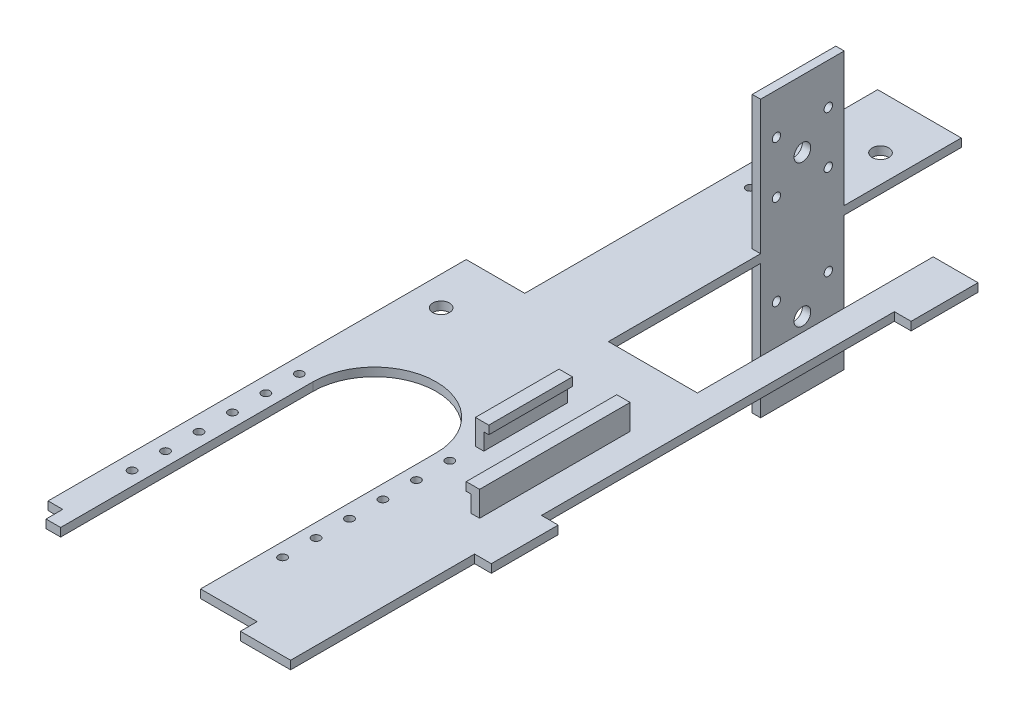
from build123d import *

# Parameters (mm, degrees)
SKETCH1_W                = 60
SKETCH1_H                = 5
BOSS_EXTRUDE1_DEPTH      = 391
SKETCH3_W                = 250
SKETCH3_H                = 5
BOSS_EXTRUDE2_DEPTH      = 95
SKETCH4_R                = 2.5
CUT_EXTRUDE1_DEPTH       = 95
SKETCH5_W                = 50
SKETCH5_H                = 141
BOSS_EXTRUDE3_DEPTH      = 5
SKETCH6_W                = 5
SKETCH6_H                = 50
BOSS_EXTRUDE4_DEPTH      = 80
SKETCH7_R                = 5
CUT_EXTRUDE2_DEPTH       = 40
CUT_EXTRUDE3_DEPTH       = 10
SKETCH11_W               = 40
SKETCH11_H               = 5
BOSS_EXTRUDE5_DEPTH      = 10
SKETCH12_W               = 30
SKETCH12_H               = 5
SKETCH12_W_2             = 17.5
BOSS_EXTRUDE6_DEPTH      = 10
SKETCH14_W               = 9
SKETCH14_H               = 5
CUT_EXTRUDE4_DEPTH       = 10
SKETCH15_W               = 5
SKETCH15_H               = 90
SKETCH15_H_2             = 50
BOSS_EXTRUDE7_DEPTH      = 15
BOSS_EXTRUDE7_DEPTH_BACK = 20
SKETCH16_W               = 50
SKETCH16_H               = 5
BOSS_EXTRUDE8_DEPTH      = 3
SKETCH18_W               = 90
SKETCH18_H               = 5
BOSS_EXTRUDE9_DEPTH      = 3
SKETCH19_R               = 2.5
CUT_EXTRUDE5_DEPTH       = 28
SKETCH20_W               = 50
SKETCH20_H               = 4.954602057
BOSS_EXTRUDE10_DEPTH     = 70
SKETCH21_R               = 5
CUT_EXTRUDE6_DEPTH       = 70
SKETCH22_R               = 2.5
CUT_EXTRUDE7_DEPTH       = 10
SKETCH23_R               = 5
CUT_EXTRUDE8_DEPTH       = 10


with BuildPart() as part:
    # Sketch1 → Boss-Extrude1 (new body)
    with BuildSketch(Plane.XY):
        Rectangle(SKETCH1_W, SKETCH1_H)
    extrude(amount=BOSS_EXTRUDE1_DEPTH)

    # Sketch3 → Boss-Extrude2 (add)
    with BuildSketch(Plane.ZY.offset(30)):
        with Locations((266, 0)):
            Rectangle(SKETCH3_W, SKETCH3_H)
    extrude(amount=BOSS_EXTRUDE2_DEPTH)

    # Sketch4 → Cut-Extrude1 (cut)
    with BuildSketch(Plane.XZ.offset(2.5)):
        with Locations((-115.67, 250.12)):
            Circle(SKETCH4_R)
        with Locations((-25.67, 250.12)):
            Circle(SKETCH4_R)
        with Locations((-25.67, 270.12)):
            Circle(SKETCH4_R)
        with Locations((-25.67, 290.12)):
            Circle(SKETCH4_R)
        with Locations((-25.67, 310.12)):
            Circle(SKETCH4_R)
        with Locations((-25.67, 330.12)):
            Circle(SKETCH4_R)
        with Locations((-25.67, 350.12)):
            Circle(SKETCH4_R)
        with Locations((-115.67, 270.12)):
            Circle(SKETCH4_R)
        with Locations((-115.67, 290.12)):
            Circle(SKETCH4_R)
        with Locations((-115.67, 310.12)):
            Circle(SKETCH4_R)
        with Locations((-115.67, 330.12)):
            Circle(SKETCH4_R)
        with Locations((-115.67, 350.12)):
            Circle(SKETCH4_R)
        with BuildLine():
            Line((-33.84, 391), (-33.84, 250.12))
            ThreePointArc((-33.84, 250.12), (-70.67, 213.29), (-107.5, 250.12))
            Line((-107.5, 250.12), (-107.5, 391))
            ThreePointArc((-107.5, 391), (-70.67, 427.83), (-33.84, 391))
        make_face()
    extrude(amount=-CUT_EXTRUDE1_DEPTH, mode=Mode.SUBTRACT)

    # Sketch5 → Boss-Extrude3 (add)
    with BuildSketch(Plane.XZ.offset(2.5)):
        with Locations((-65, 70.5)):
            Rectangle(SKETCH5_W, SKETCH5_H)
    extrude(amount=-BOSS_EXTRUDE3_DEPTH)

    # Sketch6 → Boss-Extrude4 (add)
    with BuildSketch(Plane.XZ.offset(2.5)):
        with Locations((-42.5, 25)):
            Rectangle(SKETCH6_W, SKETCH6_H)
    boss_extrude4 = extrude(amount=BOSS_EXTRUDE4_DEPTH)

    # Sketch7 → Cut-Extrude2 (cut)
    with BuildSketch(Plane.ZY.offset(45)):
        with Locations((25, -42.5)):
            Circle(SKETCH7_R)
    cut_extrude2 = extrude(amount=-CUT_EXTRUDE2_DEPTH, mode=Mode.SUBTRACT)

    # Sketch8 → Cut-Extrude3 (cut)
    with BuildSketch(Plane(origin=(0, -2.5, 0), x_dir=(-1, 0, 0), z_dir=(0, -1, 0))):
        Polygon((30, -141), (0, -141), (-13.214015024, -141), (-13.214015024, 0), (0, 0), (30, 0), align=None)
    extrude(amount=-CUT_EXTRUDE3_DEPTH, mode=Mode.SUBTRACT)

    # Sketch11 → Boss-Extrude5 (add)
    with BuildSketch(Plane(origin=(30, 0, 0), x_dir=(0, 0, -1), z_dir=(1, 0, 0))):
        with Locations((-20, 0)):
            Rectangle(SKETCH11_W, SKETCH11_H)
        with Locations((-271, 0)):
            Rectangle(SKETCH11_W, SKETCH11_H)
    extrude(amount=BOSS_EXTRUDE5_DEPTH)

    # Sketch12 → Boss-Extrude6 (add)
    with BuildSketch(Plane.XY.offset(391)):
        with Locations((15, 0)):
            Rectangle(SKETCH12_W, SKETCH12_H)
        with Locations((-116.25, 0)):
            Rectangle(SKETCH12_W_2, SKETCH12_H)
    extrude(amount=BOSS_EXTRUDE6_DEPTH)

    # Mirror1: Boss-Extrude4, Cut-Extrude2 across plane
    add(boss_extrude4.mirror(Plane.ZX))
    add(cut_extrude2.mirror(Plane.ZX), mode=Mode.SUBTRACT)

    # Sketch14 → Cut-Extrude4 (cut)
    with BuildSketch(Plane.XY.offset(401)):
        with Locations((-120.75, 0)):
            Rectangle(SKETCH14_W, SKETCH14_H)
    extrude(amount=-CUT_EXTRUDE4_DEPTH, mode=Mode.SUBTRACT)

    # Sketch15 → Boss-Extrude7 (add, two sides)
    with BuildSketch(Plane.XZ.offset(2.5)) as boss_extrude7_sk:
        with Locations((10.5, 226)):
            Rectangle(SKETCH15_W, SKETCH15_H)
        with Locations((-23, 210)):
            Rectangle(SKETCH15_W, SKETCH15_H_2)
    extrude(amount=BOSS_EXTRUDE7_DEPTH)
    extrude(boss_extrude7_sk.sketch, amount=-BOSS_EXTRUDE7_DEPTH_BACK)

    # Sketch16 → Boss-Extrude8 (add)
    with BuildSketch(Plane(origin=(-20.5, 0, 0), x_dir=(0, 0, -1), z_dir=(1, 0, 0))):
        with Locations((-210, -15)):
            Rectangle(SKETCH16_W, SKETCH16_H)
        with Locations((-210, 15)):
            Rectangle(SKETCH16_W, SKETCH16_H)
    extrude(amount=BOSS_EXTRUDE8_DEPTH)

    # Sketch18 → Boss-Extrude9 (add)
    with BuildSketch(Plane.ZY.offset(-8)):
        with Locations((226, 15)):
            Rectangle(SKETCH18_W, SKETCH18_H)
        with Locations((226, -15)):
            Rectangle(SKETCH18_W, SKETCH18_H)
    extrude(amount=BOSS_EXTRUDE9_DEPTH)

    # Sketch19 → Cut-Extrude5 (cut)
    with BuildSketch(Plane.ZY.offset(45)):
        with Locations((9.5, 58)):
            Circle(SKETCH19_R)
        with Locations((40.5, 58)):
            Circle(SKETCH19_R)
        with Locations((40.5, 27)):
            Circle(SKETCH19_R)
        with Locations((9.5, 27)):
            Circle(SKETCH19_R)
        with Locations((40.5, -27)):
            Circle(SKETCH19_R)
        with Locations((40.5, -58)):
            Circle(SKETCH19_R)
        with Locations((9.5, -58)):
            Circle(SKETCH19_R)
        with Locations((9.5, -27)):
            Circle(SKETCH19_R)
    extrude(amount=-CUT_EXTRUDE5_DEPTH, mode=Mode.SUBTRACT)

    # Sketch20 → Boss-Extrude10 (add)
    with BuildSketch(Plane(origin=(0, 0, 0), x_dir=(-1, 0, 0), z_dir=(0, 0, -1))):
        with Locations((65, -0.022698971)):
            Rectangle(SKETCH20_W, SKETCH20_H)
    extrude(amount=BOSS_EXTRUDE10_DEPTH)

    # Sketch21 → Cut-Extrude6 (cut)
    with BuildSketch(Plane.XZ.offset(2.5)):
        with Locations((-56.5, -38.21)):
            Circle(SKETCH21_R)
    extrude(amount=-CUT_EXTRUDE6_DEPTH, mode=Mode.SUBTRACT)

    # Sketch22 → Cut-Extrude7 (cut)
    with BuildSketch(Plane(origin=(0, 2.5, 0), x_dir=(1, 0, 0), z_dir=(0, 1, 0))):
        with Locations((-77.21, -19)):
            Circle(SKETCH22_R)
    extrude(amount=-CUT_EXTRUDE7_DEPTH, mode=Mode.SUBTRACT)

    # Sketch23 → Cut-Extrude8 (cut)
    with BuildSketch(Plane(origin=(0, 2.5, 0), x_dir=(1, 0, 0), z_dir=(0, 1, 0))):
        with Locations((-107.5, -173.5)):
            Circle(SKETCH23_R)
    extrude(amount=-CUT_EXTRUDE8_DEPTH, mode=Mode.SUBTRACT)


solid = part.part
